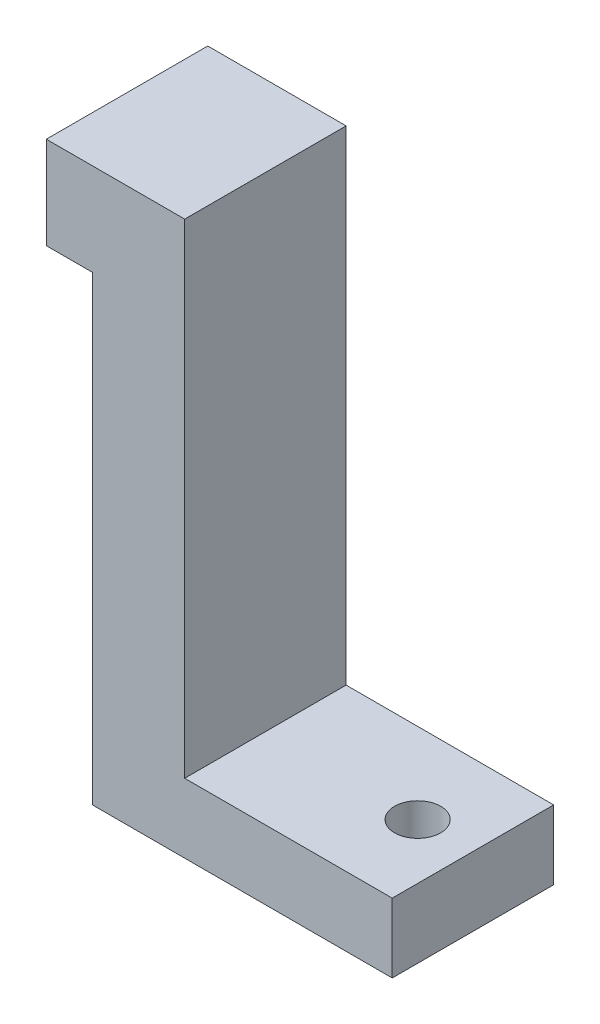
from build123d import *

# Parameters (mm, degrees)
SKETCH1_W                      = 0.5
SKETCH1_H                      = 1
SKETCH1_W_2                    = 2.25
SKETCH1_H_2                    = 0.75
BOSS_EXTRUDE1_DEPTH            = 0.75
BOSS_EXTRUDE1_DEPTH_BACK       = 1
F_0_5_0_5_DIAMETER_HOLE1_D     = 0.5
F_0_5_0_5_DIAMETER_HOLE1_DEPTH = 0.75


with BuildPart() as part:
    # Sketch1 → Boss-Extrude1 (new body, two sides)
    with BuildSketch(Plane.XY) as boss_extrude1_sk:
        Polygon((0.5, 3), (-0.5, 3), (-0.5, 2), (-0.5, -3), (0.5, -3), (0.5, -2.25), align=None)
        with Locations((-0.75, 2.5)):
            Rectangle(SKETCH1_W, SKETCH1_H)
        with Locations((1.625, -2.625)):
            Rectangle(SKETCH1_W_2, SKETCH1_H_2)
    extrude(amount=BOSS_EXTRUDE1_DEPTH)
    extrude(boss_extrude1_sk.sketch, amount=-BOSS_EXTRUDE1_DEPTH_BACK)

    # Ø0.5 (0.5) Diameter Hole1
    with Locations(Plane(origin=(0, -2.25, 0), x_dir=(1, 0, 0), z_dir=(0, 1, 0))):
        with Locations((2.15, 0.125)):
            Hole(F_0_5_0_5_DIAMETER_HOLE1_D / 2, depth=F_0_5_0_5_DIAMETER_HOLE1_DEPTH)


solid = part.part
